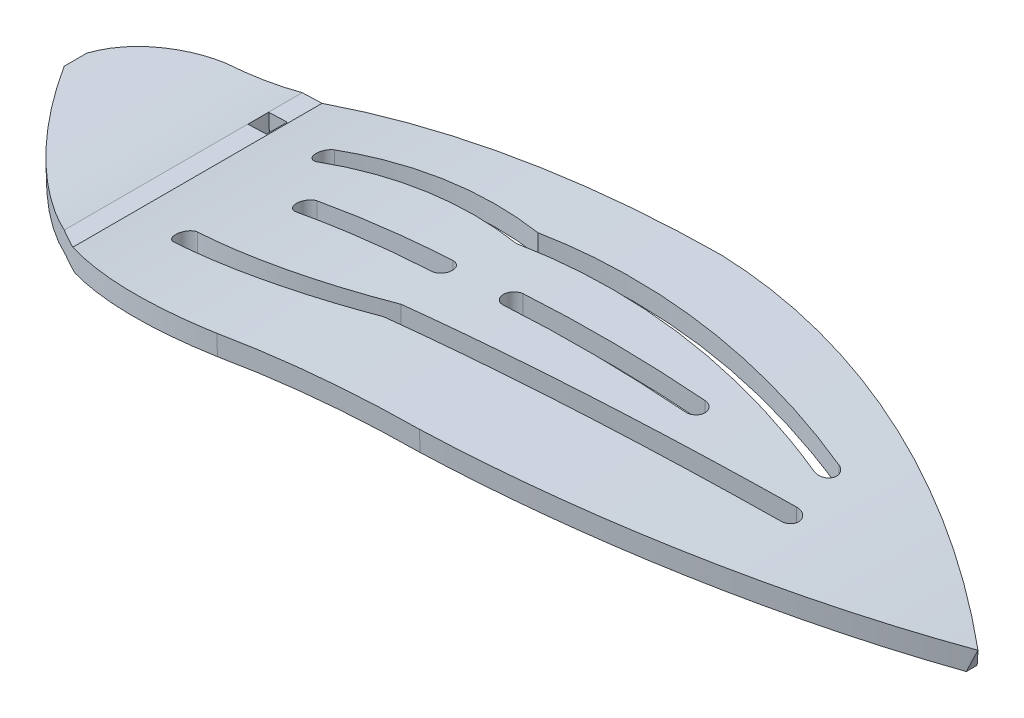
from build123d import *

# Parameters (mm, degrees)
BOSS_EXTRUDE1_DEPTH      = 19.05
BOSS_EXTRUDE1_DEPTH_BACK = 4.191
CUT_EXTRUDE1_DEPTH       = 90.413592179
CUT_EXTRUDE1_DEPTH_BACK  = 90.413592179
SKETCH2_W                = 87.253712628
SKETCH2_H                = 39.813319923
CUT_EXTRUDE2_DEPTH       = 19.05
CUT_EXTRUDE2_DEPTH_BACK  = 19.05
SKETCH3_W                = 1.428322818
SKETCH3_H                = 1.598014705
CUT_EXTRUDE3_DEPTH       = 90.506248835
CUT_EXTRUDE3_DEPTH_BACK  = 90.506248835


with BuildPart() as part:
    # Sketch1 → Boss-Extrude1 (new, two sides: drawn at the far end of the back side and taken through both)
    with BuildSketch(Plane.XY.offset(-BOSS_EXTRUDE1_DEPTH_BACK)):
        with BuildLine():
            Line((-75.189237024, -5.096374737), (-73.665237024, -5.043705171))
            ThreePointArc((-73.665237024, -5.043705171), (-42.636952293, 0.217377617), (-11.542527873, -4.637539006))
            Line((-11.542527873, -4.637539006), (-12.016580594, -6.085934677))
            ThreePointArc((-12.016580594, -6.085934677), (-42.739704949, -1.307392681), (-73.385520331, -6.558947999))
            Line((-73.385520331, -6.558947999), (-74.965667148, -6.613558005))
            ThreePointArc((-74.965667148, -6.613558005), (-81.004050329, -7.593414774), (-87.118989346, -7.421044375))
            Line((-87.118989346, -7.421044375), (-86.932454331, -5.908503239))
            ThreePointArc((-86.932454331, -5.908503239), (-81.021793865, -6.067120464), (-75.189237024, -5.096374737))
        make_face()
    extrude(amount=BOSS_EXTRUDE1_DEPTH + BOSS_EXTRUDE1_DEPTH_BACK)

    # Sketch2 → Cut-Extrude1 (cut, two sides: drawn at the far end of the back side and taken through both)
    with BuildSketch(Plane(origin=(0.138860316, -4.017939298, 0), x_dir=(-0.9994033347691804, -0.03453946224598228, 0), z_dir=(0.03453946224598228, -0.9994033347691804, 0)).offset(-CUT_EXTRUDE1_DEPTH_BACK)):
        with Locations((49.508356896, -7.260136502)):
            Rectangle(SKETCH2_W, SKETCH2_H)
        with BuildLine():
            Line((42.893945954, -19.05), (58.535995628, -19.05))
            ThreePointArc((58.535995628, -19.05), (75.136021198, -14.244685293), (87.323327356, -1.992278715))
            ThreePointArc((87.323327356, -1.992278715), (85.416060887, 2.217888864), (81.236346917, 4.191))
            Line((81.236346917, 4.191), (42.893945954, 4.191))
            ThreePointArc((42.893945954, 4.191), (26.378637692, 0.840637304), (11.695818951, -7.4295))
            ThreePointArc((11.695818951, -7.4295), (26.325842273, -15.841379758), (42.893945954, -19.05))
        make_face(mode=Mode.SUBTRACT)
    extrude(amount=CUT_EXTRUDE1_DEPTH + CUT_EXTRUDE1_DEPTH_BACK, mode=Mode.SUBTRACT)

    # Sketch3 → Cut-Extrude2 (cut, two sides: drawn at the far end of the back side and taken through both)
    with BuildSketch(Plane(origin=(0.138860316, -4.017939298, 0), x_dir=(0.9994033347691804, 0.03453946224598228, 0), z_dir=(0.03453946224598228, -0.9994033347691804, 0)).offset(-CUT_EXTRUDE2_DEPTH_BACK)):
        with Locations((-74.593800237, -0.799007353)):
            Rectangle(SKETCH3_W, SKETCH3_H)
    extrude(amount=CUT_EXTRUDE2_DEPTH + CUT_EXTRUDE2_DEPTH_BACK, mode=Mode.SUBTRACT)

    # Sketch4 → Cut-Extrude3 (cut, two sides: drawn at the far end of the back side and taken through both)
    with BuildSketch(Plane(origin=(0, 0, 0), x_dir=(1, 0, 0), z_dir=(0, 1, 0)).offset(-CUT_EXTRUDE3_DEPTH_BACK)):
        with BuildLine():
            Line((-64.893542216, -6.597323199), (-53.662481079, -7.351648201))
            ThreePointArc((-53.662481079, -7.351648201), (-52.851129929, -6.642425168), (-53.560352962, -5.831074017))
            Line((-53.560352962, -5.831074017), (-64.791414099, -5.076749016))
            ThreePointArc((-64.791414099, -5.076749016), (-65.60276525, -5.785972049), (-64.893542216, -6.597323199))
        make_face()
        with BuildLine():
            Line((-48.16351423, -7.353361109), (-34.166594754, -7.353361109))
            ThreePointArc((-34.166594754, -7.353361109), (-33.404594754, -6.591361109), (-34.166594754, -5.829361109))
            Line((-34.166594754, -5.829361109), (-48.16351423, -5.829361109))
            ThreePointArc((-48.16351423, -5.829361109), (-48.92551423, -6.591361109), (-48.16351423, -7.353361109))
        make_face()
        with BuildLine():
            ThreePointArc((-68.534997951, -12.362450574), (-60.444707089, -13.294377363), (-52.352141863, -12.382411445))
            ThreePointArc((-52.352141863, -12.382411445), (-38.341637279, -11.721973531), (-24.464171754, -9.685710393))
            ThreePointArc((-24.464171754, -9.685710393), (-23.864251009, -8.790510359), (-24.759451042, -8.190589614))
            ThreePointArc((-24.759451042, -8.190589614), (-38.575832063, -10.213483586), (-52.524637961, -10.857920208))
            ThreePointArc((-52.524637961, -10.857920208), (-60.356328328, -11.770376603), (-68.190325048, -10.877938334))
            ThreePointArc((-68.190325048, -10.877938334), (-69.104917619, -11.447858003), (-68.534997951, -12.362450574))
        make_face()
        with BuildLine():
            ThreePointArc((-25.724196054, -3.936751805), (-38.706541391, -1.164656942), (-51.978446223, -0.877703144))
            ThreePointArc((-51.978446223, -0.877703144), (-60.183282807, 0.29192564), (-68.463888537, -0.052956388))
            ThreePointArc((-68.463888537, -0.052956388), (-69.117907874, -0.9094298), (-68.261434462, -1.563449137))
            ThreePointArc((-68.261434462, -1.563449137), (-60.142415983, -1.236181897), (-52.102798554, -2.415213913))
            ThreePointArc((-52.102798554, -2.415213913), (-39.000033907, -2.664871884), (-26.181471193, -5.390531516))
            ThreePointArc((-26.181471193, -5.390531516), (-25.225943768, -4.892279229), (-25.724196054, -3.936751805))
        make_face()
    extrude(amount=CUT_EXTRUDE3_DEPTH + CUT_EXTRUDE3_DEPTH_BACK, mode=Mode.SUBTRACT)


solid = part.part
